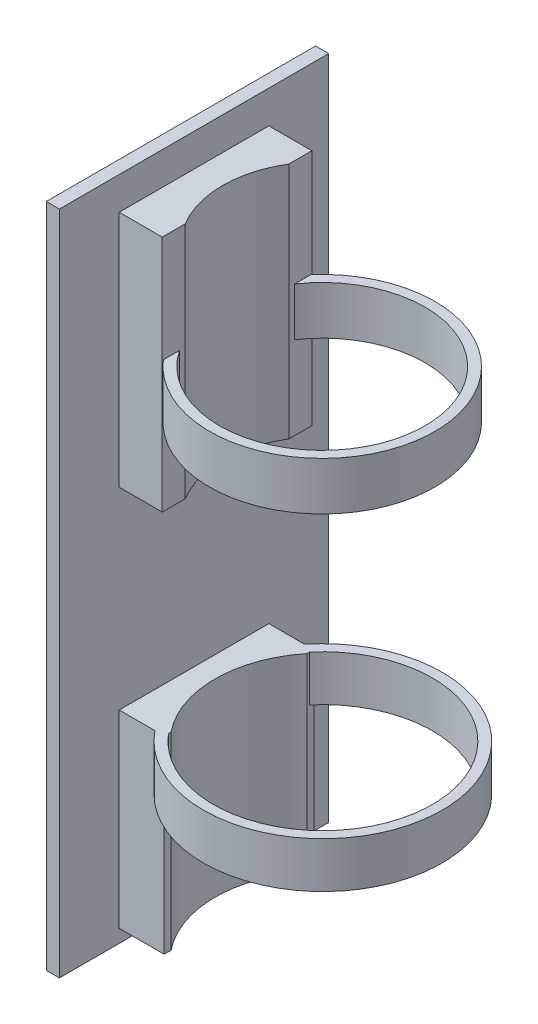
from build123d import *

# Parameters (mm, degrees)
SKETCH1_W                      = 6.866677178
SKETCH1_H                      = 28.893583938
BOSS_EXTRUDE1_DEPTH            = 11.43
SKETCH1_W_2                    = 6.571343666
SKETCH1_H_2                    = 36.38751909
BOSS_EXTRUDE1_2_DEPTH          = 11.43
BOSS_EXTRUDE2_DEPTH            = 20.574
CUT_EXTRUDE1_REACH             = 110.537
SKETCH2_R                      = 16.5
CUT_EXTRUDE1_DIRECTION_2_DEPTH = 35.052
CUT_EXTRUDE4_REACH             = 75.978
SKETCH3_R                      = 15.24
BOSS_EXTRUDE6_START            = -12.7
SKETCH15_R                     = 17.215000066
SKETCH15_R_2                   = 15.715000066
BOSS_EXTRUDE6_DEPTH            = 7.366
SKETCH16_R                     = 18.250000028
SKETCH16_R_2                   = 16.750000028
BOSS_EXTRUDE7_DEPTH            = 7


with BuildPart() as part:
    # Sketch1 → Boss-Extrude1 (new, symmetric)
    with BuildSketch(Plane.XY):
        with Locations((-32.040465484, -10.249157812)):
            Rectangle(SKETCH1_W, SKETCH1_H)
    extrude(amount=BOSS_EXTRUDE1_DEPTH, both=True)



with BuildPart() as body_2:
    # Sketch1 → Boss-Extrude1 2 (new, symmetric)
    with BuildSketch(Plane.XY):
        with Locations((-32.18813224, 51.873158257)):
            Rectangle(SKETCH1_W_2, SKETCH1_H_2)
    extrude(amount=BOSS_EXTRUDE1_2_DEPTH, both=True)


with BuildPart() as part_1:
    add(part.part)

    add(body_2.part)  # Boss-Extrude2 merges body 2
    # Sketch1_3 → Boss-Extrude2 (add, symmetric)
    with BuildSketch(Plane.XY):
        Polygon((-37.473804073, -26.695949781), (-35.473804073, -26.695949781), (-35.473804073, -24.695949781), (-35.473804073, 4.197634157), (-35.473804073, 33.679398712), (-35.473804073, 70.066917802), (-35.473804073, 75.066917802), (-37.473804073, 75.066917802), align=None)
    extrude(amount=BOSS_EXTRUDE2_DEPTH, both=True)

    # Sketch2 → Cut-Extrude1 (cut, up to next)
    with BuildSketch(Plane.XZ.offset(24.695949781), mode=Mode.PRIVATE) as cut_extrude1_sk1:
        with Locations((-15.773804073, 0)):
            Circle(SKETCH2_R)
    cut_extrude1_tool1 = extrude(cut_extrude1_sk1.sketch, amount=-CUT_EXTRUDE1_REACH, mode=Mode.PRIVATE) & part_1.part
    add(cut_extrude1_tool1.solids().sort_by_distance((-15.773804, -24.69595, 0))[0], mode=Mode.SUBTRACT)

    # Sketch2 → Cut-Extrude1 direction 2 (cut)
    with BuildSketch(Plane.XZ.offset(24.695949781)):
        with Locations((-15.773804073, 0)):
            Circle(SKETCH2_R)
    extrude(amount=CUT_EXTRUDE1_DIRECTION_2_DEPTH, mode=Mode.SUBTRACT)

    # Sketch3 → Cut-Extrude4 (cut, up to next)
    with BuildSketch(Plane.XZ.offset(-33.679398712), mode=Mode.PRIVATE) as cut_extrude4_sk1:
        with Locations((-15.883804073, 0)):
            Circle(SKETCH3_R)
    cut_extrude4_tool1 = extrude(cut_extrude4_sk1.sketch, amount=-CUT_EXTRUDE4_REACH, mode=Mode.PRIVATE) & part_1.part
    add(cut_extrude4_tool1.solids().sort_by_distance((-15.883804, 33.679399, 0))[0], mode=Mode.SUBTRACT)

    # Sketch15 → Boss-Extrude6 (add)
    with BuildSketch(Plane.XZ.offset(-33.679398712).offset(BOSS_EXTRUDE6_START)):
        with Locations((-15.883804073, 0)):
            Circle(SKETCH15_R)
        with Locations((-15.883804073, 0)):
            Circle(SKETCH15_R_2, mode=Mode.SUBTRACT)
    extrude(amount=-BOSS_EXTRUDE6_DEPTH)

    # Sketch16 → Boss-Extrude7 (add)
    with BuildSketch(Plane(origin=(0, 4.197634157, 0), x_dir=(1, 0, 0), z_dir=(0, 1, 0))):
        with Locations((-15.787690473, 0)):
            Circle(SKETCH16_R)
        with Locations((-15.787690473, 0)):
            Circle(SKETCH16_R_2, mode=Mode.SUBTRACT)
    extrude(amount=-BOSS_EXTRUDE7_DEPTH)


solid = part_1.part
